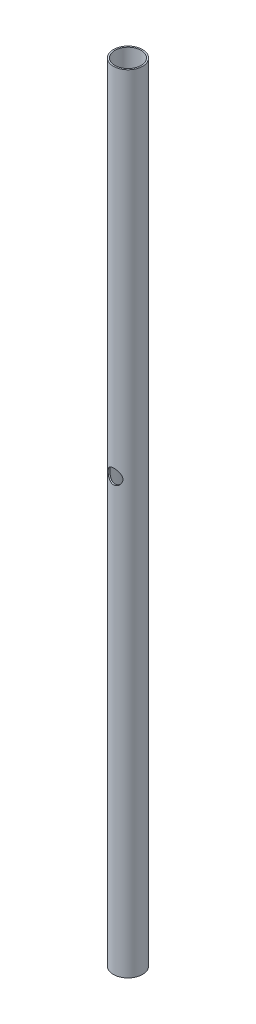
from build123d import *

# Parameters (mm, degrees)
SKETCH1_R                  = 0.5
SKETCH1_R_2                = 0.45
BOSS_EXTRUDE1_DEPTH        = 27
F_0_5_0_5_DIAMETER_HOLE1_D = 0.5


with BuildPart() as part:
    # Sketch1 → Boss-Extrude1 (new body)
    with BuildSketch(Plane(origin=(0, 0, 0), x_dir=(1, 0, 0), z_dir=(0, 1, 0))):
        Circle(SKETCH1_R)
        Circle(SKETCH1_R_2, mode=Mode.SUBTRACT)
    extrude(amount=BOSS_EXTRUDE1_DEPTH)

    # Ø0.5 (0.5) Diameter Hole1 (through all)
    with Locations(Plane(origin=(-0.006079101, 14.81, -0.499963043), x_dir=(-0.999926086, 0, 0.012158201), z_dir=(-0.012158201, 0, -0.999926086))):
        with Locations((0, 0)):
            Hole(F_0_5_0_5_DIAMETER_HOLE1_D / 2)


solid = part.part
